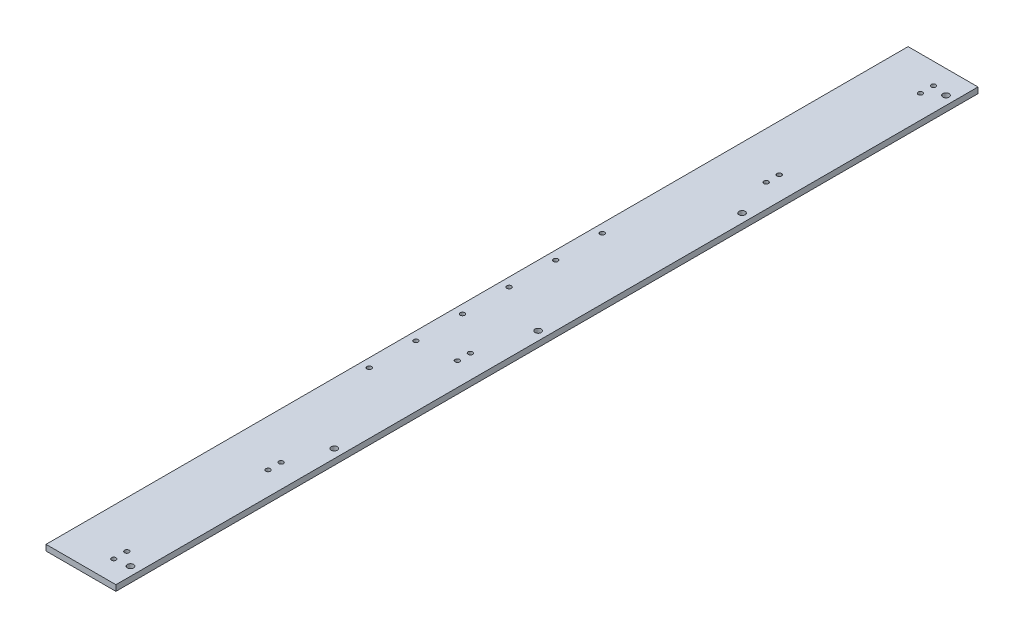
from build123d import *

# Parameters (mm, degrees)
SKETCH1_W               = 76.2
SKETCH1_H               = 6.35
BOSS_EXTRUDE1_DEPTH     = 939.8
SKETCH2_R               = 2.4638
CUT_EXTRUDE1_DEPTH      = 7.35
LPATTERN1_COUNT         = 6
LPATTERN1_PITCH         = 50.8
SKETCH3_R               = 2.4638
CUT_EXTRUDE2_DEPTH      = 7.35
SKETCH4_R               = 2.4638
CUT_EXTRUDE3_DEPTH      = 7.35
SKETCH5_R               = 3.3655
CUT_EXTRUDE4_DEPTH      = 1
CUT_EXTRUDE4_DEPTH_BACK = 7.35


with BuildPart() as part:
    # Sketch1 → Boss-Extrude1 (new body)
    with BuildSketch(Plane.XY):
        with Locations((38.1, 3.175)):
            Rectangle(SKETCH1_W, SKETCH1_H)
    extrude(amount=BOSS_EXTRUDE1_DEPTH)

    # Sketch2 → Cut-Extrude1 (cut, through all)
    with BuildSketch(Plane(origin=(0, 6.35, 0), x_dir=(1, 0, 0), z_dir=(0, 1, 0))):
        with Locations((9.525, -596.9)):
            Circle(SKETCH2_R)
    cut_extrude1 = extrude(amount=-CUT_EXTRUDE1_DEPTH, mode=Mode.SUBTRACT)

    # LPattern1: Cut-Extrude1 ×6
    with Locations(*[(0, 0, -i * LPATTERN1_PITCH) for i in range(1, LPATTERN1_COUNT)]):
        add(cut_extrude1, mode=Mode.SUBTRACT)

    # Sketch3 → Cut-Extrude2 (cut, through all)
    with BuildSketch(Plane(origin=(0, 6.35, 0), x_dir=(1, 0, 0), z_dir=(0, 1, 0))):
        with Locations((50.8, -527.939)):
            Circle(SKETCH3_R)
        with Locations((50.8, -542.163)):
            Circle(SKETCH3_R)
    extrude(amount=-CUT_EXTRUDE2_DEPTH, mode=Mode.SUBTRACT)

    # Sketch4 → Cut-Extrude3 (cut, through all)
    with BuildSketch(Plane(origin=(0, 6.35, 0), x_dir=(1, 0, 0), z_dir=(0, 1, 0))):
        with Locations((50.8, -916.686)):
            Circle(SKETCH4_R)
        with Locations((50.8, -902.462)):
            Circle(SKETCH4_R)
        with Locations((50.8, -748.538)):
            Circle(SKETCH4_R)
        with Locations((50.8, -734.314)):
            Circle(SKETCH4_R)
    cut_extrude3 = extrude(amount=-CUT_EXTRUDE3_DEPTH, mode=Mode.SUBTRACT)

    # Mirror1: Cut-Extrude3 across plane
    add(cut_extrude3.mirror(Plane.XY.offset(469.9)), mode=Mode.SUBTRACT)

    # Sketch5 → Cut-Extrude4 (cut, two sides)
    with BuildSketch(Plane(origin=(0, 6.35, 0), x_dir=(1, 0, 0), z_dir=(0, 1, 0))) as cut_extrude4_sk:
        with Locations((66.675, -469.9)):
            Circle(SKETCH5_R)
        with Locations((66.675, -247.65)):
            Circle(SKETCH5_R)
        with Locations((66.675, -25.4)):
            Circle(SKETCH5_R)
        with Locations((66.675, -692.15)):
            Circle(SKETCH5_R)
        with Locations((66.675, -914.4)):
            Circle(SKETCH5_R)
    extrude(amount=CUT_EXTRUDE4_DEPTH, mode=Mode.SUBTRACT)
    extrude(cut_extrude4_sk.sketch, amount=-CUT_EXTRUDE4_DEPTH_BACK, mode=Mode.SUBTRACT)


solid = part.part
